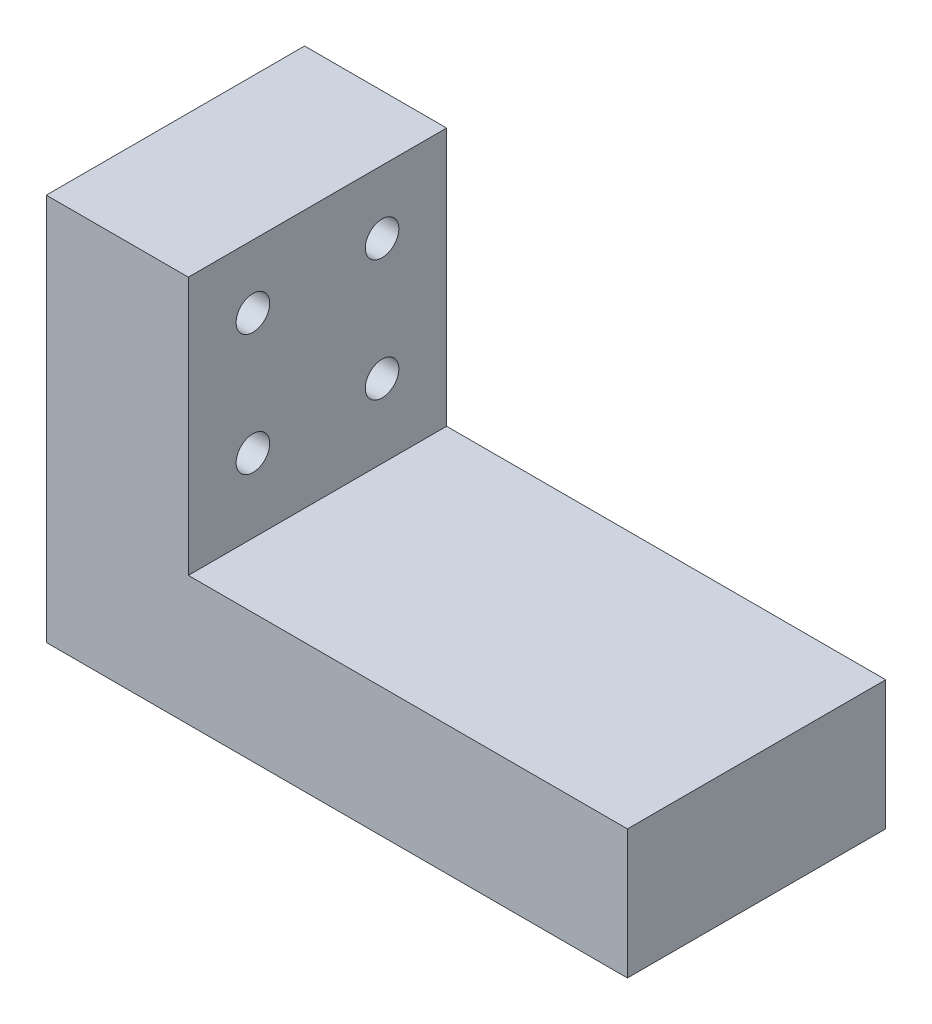
from build123d import *

# Parameters (mm, degrees)
BOSS_EXTRU_1_DEPTH      = 20
ESQUISSE2_R             = 2.8
ENL_V_MAT_EXTRU_1_DEPTH = 8.1
ENL_V_MAT_EXTRU_2_REACH = 13
ESQUISSE3_R             = 1.3


with BuildPart() as part:
    # Esquisse1 → Boss.-Extru.1 (new body)
    with BuildSketch(Plane.XY):
        Polygon((0, 0), (0, 30), (11, 30), (11, 10), (45, 10), (45, 0), align=None)
    extrude(amount=BOSS_EXTRU_1_DEPTH)

    # Esquisse2 → Enlèv. mat.-Extru.1 (cut)
    with BuildSketch(Plane.XZ):
        with Locations((17.5, 10)):
            Circle(ESQUISSE2_R)
        with Locations((37.5, 10)):
            Circle(ESQUISSE2_R)
    extrude(amount=-ENL_V_MAT_EXTRU_1_DEPTH, mode=Mode.SUBTRACT)

    # Esquisse3 → Enlèv. mat.-Extru.2 (cut, up to next)
    with BuildSketch(Plane(origin=(11, 0, 0), x_dir=(0, 0, -1), z_dir=(1, 0, 0)), mode=Mode.PRIVATE) as enl_v_mat_extru_2_sk1:
        with Locations((-15, 25.1)):
            Circle(ESQUISSE3_R)
    enl_v_mat_extru_2_tool1 = extrude(enl_v_mat_extru_2_sk1.sketch, amount=-ENL_V_MAT_EXTRU_2_REACH, mode=Mode.PRIVATE) & part.part
    add(enl_v_mat_extru_2_tool1.solids().sort_by_distance((11, 25.1, 15))[0], mode=Mode.SUBTRACT)
    # Esquisse3 → Enlèv. mat.-Extru.2 (cut, up to next)
    with BuildSketch(Plane(origin=(11, 0, 0), x_dir=(0, 0, -1), z_dir=(1, 0, 0)), mode=Mode.PRIVATE) as enl_v_mat_extru_2_sk2:
        with Locations((-5, 25.1)):
            Circle(ESQUISSE3_R)
    enl_v_mat_extru_2_tool2 = extrude(enl_v_mat_extru_2_sk2.sketch, amount=-ENL_V_MAT_EXTRU_2_REACH, mode=Mode.PRIVATE) & part.part
    add(enl_v_mat_extru_2_tool2.solids().sort_by_distance((11, 25.1, 5))[0], mode=Mode.SUBTRACT)
    # Esquisse3 → Enlèv. mat.-Extru.2 (cut, up to next)
    with BuildSketch(Plane(origin=(11, 0, 0), x_dir=(0, 0, -1), z_dir=(1, 0, 0)), mode=Mode.PRIVATE) as enl_v_mat_extru_2_sk3:
        with Locations((-5, 15.7)):
            Circle(ESQUISSE3_R)
    enl_v_mat_extru_2_tool3 = extrude(enl_v_mat_extru_2_sk3.sketch, amount=-ENL_V_MAT_EXTRU_2_REACH, mode=Mode.PRIVATE) & part.part
    add(enl_v_mat_extru_2_tool3.solids().sort_by_distance((11, 15.7, 5))[0], mode=Mode.SUBTRACT)
    # Esquisse3 → Enlèv. mat.-Extru.2 (cut, up to next)
    with BuildSketch(Plane(origin=(11, 0, 0), x_dir=(0, 0, -1), z_dir=(1, 0, 0)), mode=Mode.PRIVATE) as enl_v_mat_extru_2_sk4:
        with Locations((-15, 15.7)):
            Circle(ESQUISSE3_R)
    enl_v_mat_extru_2_tool4 = extrude(enl_v_mat_extru_2_sk4.sketch, amount=-ENL_V_MAT_EXTRU_2_REACH, mode=Mode.PRIVATE) & part.part
    add(enl_v_mat_extru_2_tool4.solids().sort_by_distance((11, 15.7, 15))[0], mode=Mode.SUBTRACT)


solid = part.part
